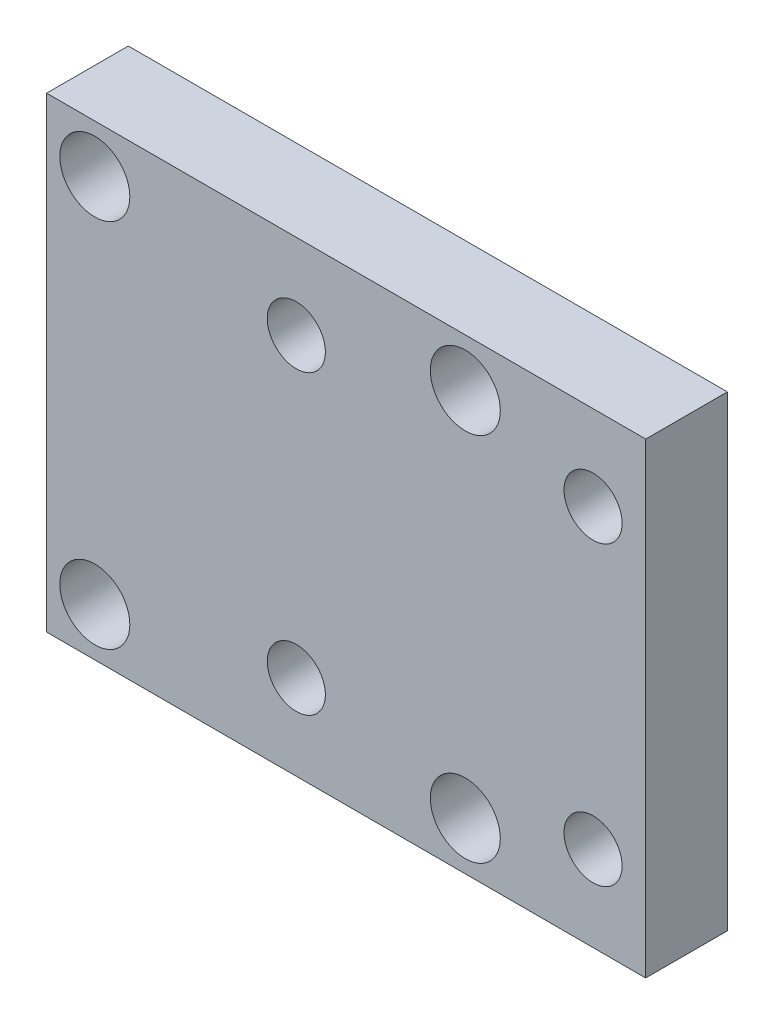
from build123d import *

# Parameters (mm, degrees)
SKETCH1_W           = 51.34
SKETCH1_H           = 40
BOSS_EXTRUDE1_DEPTH = 7
SKETCH2_R           = 2
CUT_EXTRUDE2_DEPTH  = 8
SKETCH8_R           = 3
CUT_EXTRUDE6_DEPTH  = 6
SKETCH9_R           = 2.49
CUT_EXTRUDE7_DEPTH  = 7


with BuildPart() as part:
    # Sketch1 → Boss-Extrude1 (new body)
    with BuildSketch(Plane.XY):
        with Locations((-39.76, -20)):
            Rectangle(SKETCH1_W, SKETCH1_H)
    extrude(amount=BOSS_EXTRUDE1_DEPTH)

    # Sketch2 → Cut-Extrude2 (cut, through all)
    with BuildSketch(Plane.XY):
        with Locations((-61.3, -35.875)):
            Circle(SKETCH2_R)
        with Locations((-29.55, -35.875)):
            Circle(SKETCH2_R)
        with Locations((-29.55, -4.125)):
            Circle(SKETCH2_R)
        with Locations((-61.3, -4.125)):
            Circle(SKETCH2_R)
    extrude(amount=CUT_EXTRUDE2_DEPTH, mode=Mode.SUBTRACT)

    # Sketch8 → Cut-Extrude6 (cut)
    with BuildSketch(Plane.XY.offset(7)):
        with Locations((-61.3, -4.125)):
            Circle(SKETCH8_R)
        with Locations((-29.55, -4.125)):
            Circle(SKETCH8_R)
        with Locations((-29.55, -35.875)):
            Circle(SKETCH8_R)
        with Locations((-61.3, -35.875)):
            Circle(SKETCH8_R)
    extrude(amount=-CUT_EXTRUDE6_DEPTH, mode=Mode.SUBTRACT)

    # Sketch9 → Cut-Extrude7 (cut)
    with BuildSketch(Plane.XY.offset(7)):
        with Locations((-44.030806884, -7.27)):
            Circle(SKETCH9_R)
        with Locations((-18.600806884, -7.27)):
            Circle(SKETCH9_R)
        with Locations((-44.030806884, -32.7)):
            Circle(SKETCH9_R)
        with Locations((-18.600806884, -32.7)):
            Circle(SKETCH9_R)
    extrude(amount=-CUT_EXTRUDE7_DEPTH, mode=Mode.SUBTRACT)


solid = part.part
